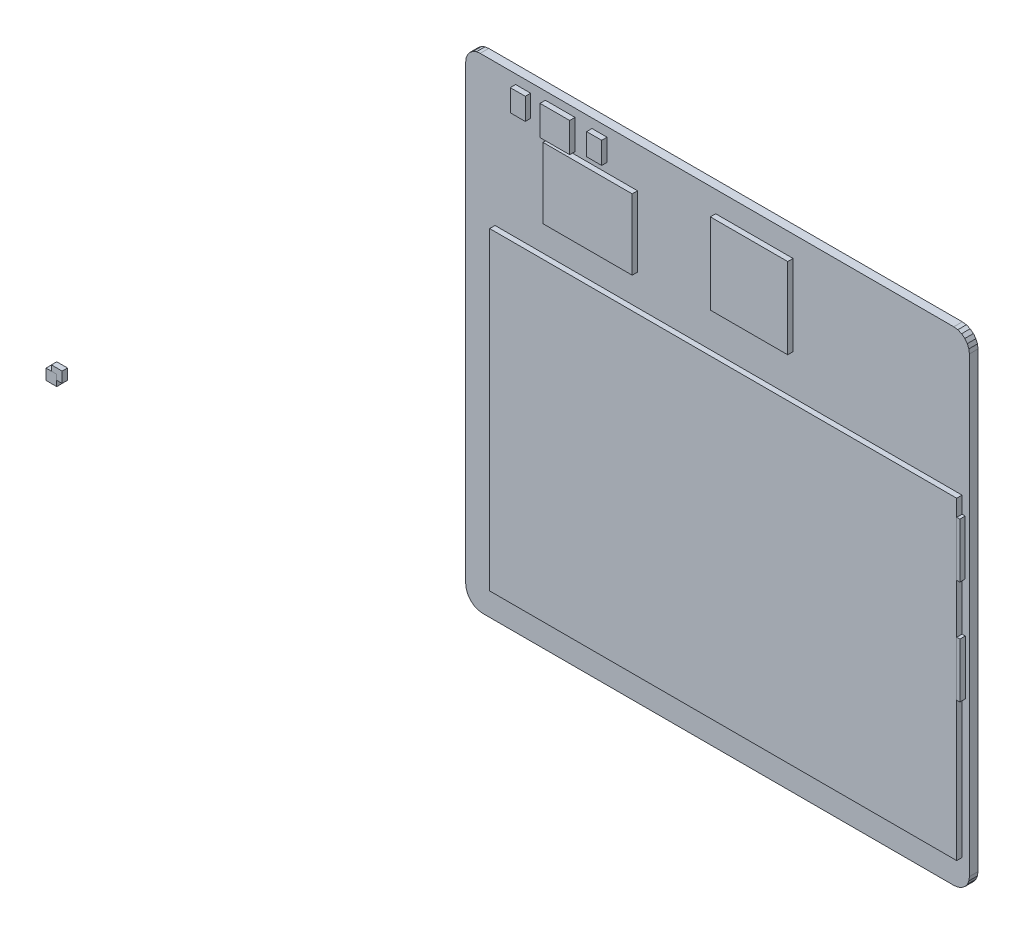
from build123d import *

# Parameters (mm, degrees)
BOARD_DEPTH                 = 1.6
ESQUISSE2_W                 = 1.9914
ESQUISSE2_H                 = 2.9968
F_0603_CAP_1_DEPTH          = 1
ESQUISSE3_W                 = 2.9968
ESQUISSE3_H                 = 1.9914
F_0603_CAP_2_DEPTH          = 1
ESQUISSE4_W                 = 2.9968
ESQUISSE4_H                 = 1.9914
F_0603_CAP_3_DEPTH          = 1
ESQUISSE5_W                 = 2.9968
ESQUISSE5_H                 = 1.9914
F_0603_CAP_4_DEPTH          = 1
ESQUISSE6_W                 = 2
ESQUISSE6_H                 = 2
DUMMY_1_DEPTH               = 1
ESQUISSE7_W                 = 2
ESQUISSE7_H                 = 2
DUMMY_2_DEPTH               = 1
ESQUISSE8_W                 = 2.8
ESQUISSE8_H                 = 4.0635
U_FL_1_DEPTH                = 1
ESQUISSE9_W                 = 2.8
ESQUISSE9_H                 = 4.0635
U_FL_2_DEPTH                = 1
ESQUISSE10_W                = 2.6416
ESQUISSE10_H                = 10.16
EXTRUDE_1X04_1_DEPTH        = 1
ESQUISSE11_W                = 2.6416
ESQUISSE11_H                = 10.16
EXTRUDE_1X04_2_DEPTH        = 1
ESQUISSE14_W                = 87.0635
ESQUISSE14_H                = 58.5
RPI3_1_DEPTH                = 1
ESQUISSE15_W                = 10.623856
ESQUISSE15_H                = 6.6675
SO016_1_DEPTH               = 1
ESQUISSE16_W                = 5.5302
ESQUISSE16_H                = 5.5302
QFN32_5X5MM_1_DEPTH         = 1
ESQUISSE17_W                = 16.625597
ESQUISSE17_H                = 13.1318
S1216_24PIN_PACKAGE_1_DEPTH = 1
ESQUISSE18_W                = 14.427
ESQUISSE18_H                = 15.054
PN87520_1_DEPTH             = 1
ESQUISSE19_W                = 3.2635
ESQUISSE19_H                = 2.627
CRYSTAL_SMD_3_2X2_5_1_DEPTH = 1


with BuildPart() as part:
    # Esquisse1 → BOARD (new body)
    with BuildSketch(Plane.XY):
        Polygon((0, 87.475991), (0, 3.194544), (0.108851, 2.367735), (0.427988, 1.597272), (0.93566, 0.93566), (1.597272, 0.427988), (2.367735, 0.108851), (3.194544, 0), (91.011053, 0), (91.756179, 0.098098), (92.450527, 0.385706), (93.046776, 0.843224), (93.504294, 1.439473), (93.791902, 2.133821), (93.89, 2.878947), (93.89, 87.252531), (93.79059, 88.007628), (93.499133, 88.711266), (93.035493, 89.315493), (92.431266, 89.779133), (91.727628, 90.07059), (90.972531, 90.17), (2.694009, 90.17), (1.996748, 90.078204), (1.347005, 89.809071), (0.789057, 89.380943), (0.360929, 88.822995), (0.091796, 88.173252), align=None)
    extrude(amount=BOARD_DEPTH)


with BuildPart() as body_2:
    # Esquisse2 → 0603-CAP-1 (new body)
    with BuildSketch(Plane.XY.offset(1.6)):
        with Locations((24.0353, 41.0246)):
            Rectangle(ESQUISSE2_W, ESQUISSE2_H)
    extrude(amount=F_0603_CAP_1_DEPTH)


with BuildPart() as body_3:
    # Esquisse3 → 0603-CAP-2 (new body)
    with BuildSketch(Plane.XY.offset(1.6)):
        with Locations((20.9072, 37.8045)):
            Rectangle(ESQUISSE3_W, ESQUISSE3_H)
    extrude(amount=F_0603_CAP_2_DEPTH)


with BuildPart() as body_4:
    # Esquisse4 → 0603-CAP-3 (new body)
    with BuildSketch(Plane.XY.offset(1.6)):
        with Locations((23.9876, 37.8091)):
            Rectangle(ESQUISSE4_W, ESQUISSE4_H)
    extrude(amount=F_0603_CAP_3_DEPTH)


with BuildPart() as body_5:
    # Esquisse5 → 0603-CAP-4 (new body)
    with BuildSketch(Plane.XY.offset(1.6)):
        with Locations((29.3398, 27.8507)):
            Rectangle(ESQUISSE5_W, ESQUISSE5_H)
    extrude(amount=F_0603_CAP_4_DEPTH)


with BuildPart() as body_6:
    # Esquisse6 → DUMMY-1 (new body)
    with BuildSketch(Plane.XY.offset(1.6)):
        with Locations((-75.23, -0.08)):
            Rectangle(ESQUISSE6_W, ESQUISSE6_H)
    extrude(amount=DUMMY_1_DEPTH)


with BuildPart() as body_7:
    # Esquisse7 → DUMMY-2 (new body)
    with BuildSketch(Plane.XY.offset(1.6)):
        with Locations((-76.24, -1.1)):
            Rectangle(ESQUISSE7_W, ESQUISSE7_H)
    extrude(amount=DUMMY_2_DEPTH)


with BuildPart() as body_8:
    # Esquisse8 → U_FL-1 (new body)
    with BuildSketch(Plane.XY.offset(1.6)):
        with Locations((24.94, 86.42825)):
            Rectangle(ESQUISSE8_W, ESQUISSE8_H)
    extrude(amount=U_FL_1_DEPTH)


with BuildPart() as body_9:
    # Esquisse9 → U_FL-2 (new body)
    with BuildSketch(Plane.XY.offset(1.6)):
        with Locations((10.7, 86.41175)):
            Rectangle(ESQUISSE9_W, ESQUISSE9_H)
    extrude(amount=U_FL_2_DEPTH)


with BuildPart() as body_10:
    # Esquisse10 → 1X04-1 (new body)
    with BuildSketch(Plane.XY.offset(1.6)):
        with Locations((91.7792, 55.6)):
            Rectangle(ESQUISSE10_W, ESQUISSE10_H)
    extrude(amount=EXTRUDE_1X04_1_DEPTH)


with BuildPart() as body_11:
    # Esquisse11 → 1X04-2 (new body)
    with BuildSketch(Plane.XY.offset(1.6)):
        with Locations((91.7956, 36.2458)):
            Rectangle(ESQUISSE11_W, ESQUISSE11_H)
    extrude(amount=EXTRUDE_1X04_2_DEPTH)


with BuildPart() as body_12:
    # Esquisse14 → RPI3-1 (new body)
    with BuildSketch(Plane.XY.offset(1.6)):
        with Locations((48.98825, 34.52)):
            Rectangle(ESQUISSE14_W, ESQUISSE14_H)
    extrude(amount=RPI3_1_DEPTH)


with BuildPart() as body_13:
    # Esquisse15 → SO016-1 (new body)
    with BuildSketch(Plane.XY.offset(1.6)):
        with Locations((24.060372, 32.49825)):
            Rectangle(ESQUISSE15_W, ESQUISSE15_H)
    extrude(amount=SO016_1_DEPTH)


with BuildPart() as body_14:
    # Esquisse16 → QFN32-5X5MM-1 (new body)
    with BuildSketch(Plane.XY.offset(1.6)):
        with Locations((17.6119, 85.9119)):
            Rectangle(ESQUISSE16_W, ESQUISSE16_H)
    extrude(amount=QFN32_5X5MM_1_DEPTH)


with BuildPart() as body_15:
    # Esquisse17 → S1216_24PIN_PACKAGE-1 (new body)
    with BuildSketch(Plane.XY.offset(1.6)):
        with Locations((23.7128015, 76.0897)):
            Rectangle(ESQUISSE17_W, ESQUISSE17_H)
    extrude(amount=S1216_24PIN_PACKAGE_1_DEPTH)


with BuildPart() as body_16:
    # Esquisse18 → PN87520-1 (new body)
    with BuildSketch(Plane.XY.offset(1.6)):
        with Locations((53.8049, 78.7004)):
            Rectangle(ESQUISSE18_W, ESQUISSE18_H)
    extrude(amount=PN87520_1_DEPTH)


with BuildPart() as body_17:
    # Esquisse19 → CRYSTAL-SMD-3_2X2_5-1 (new body)
    with BuildSketch(Plane.XY.offset(1.6)):
        with Locations((21.05175, 40.9742)):
            Rectangle(ESQUISSE19_W, ESQUISSE19_H)
    extrude(amount=CRYSTAL_SMD_3_2X2_5_1_DEPTH)


solid = Compound([part.part, body_2.part, body_3.part, body_4.part, body_5.part, body_6.part, body_7.part, body_8.part, body_9.part, body_10.part, body_11.part, body_12.part, body_13.part, body_14.part, body_15.part, body_16.part, body_17.part])
